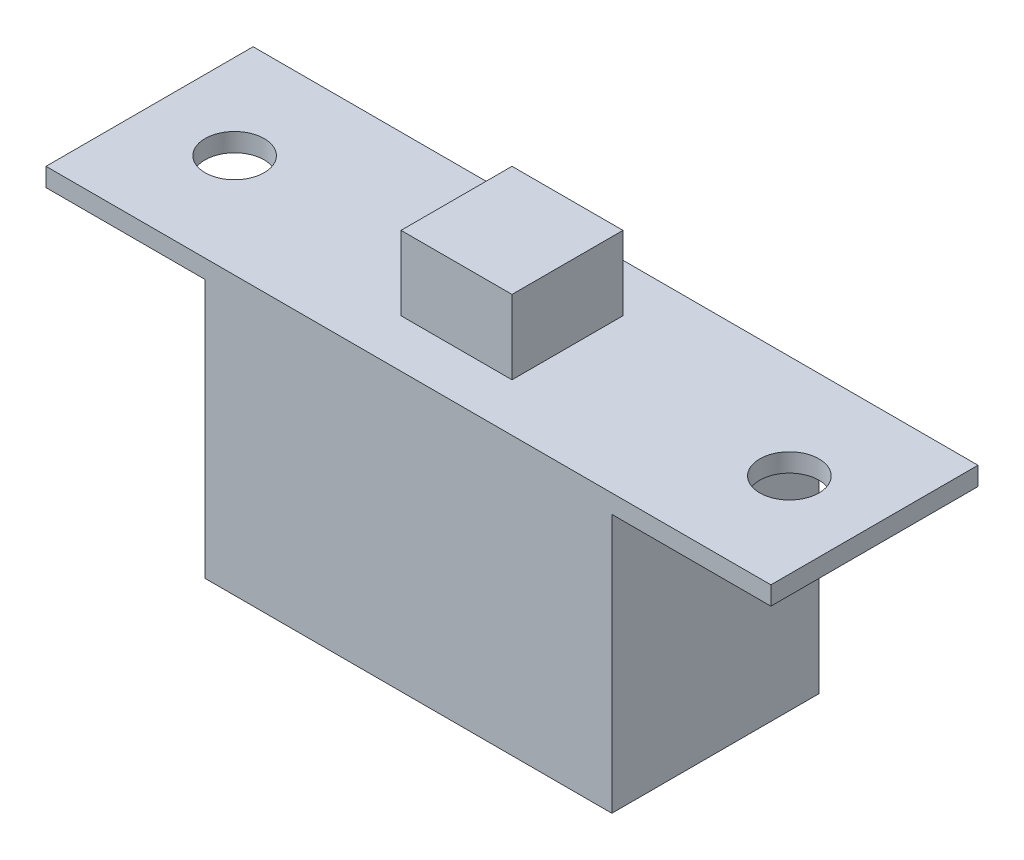
from build123d import *

# Parameters (mm, degrees)
AUFSATZ_LINEAR_AUSTRAGEN1_DEPTH = 2.8
SCHNITT_LINEAR_START            = 1.5
SKIZZE2_W                       = 3
SKIZZE2_H                       = 2
SCHNITT_LINEAR_AUSTRAGEN1_DEPTH = 2.3
M2_GEWINDEBOHRUNG1_D            = 1.6


with BuildPart() as part:
    # Skizze1 → Aufsatz-Linear austragen1 (new body, symmetric)
    with BuildSketch(Plane.XY):
        Polygon((-9.8, -2), (-1.5, -2), (-1.5, 0), (1.5, 0), (1.5, -2), (9.8, -2), (9.8, -2.5), (5.5, -2.5), (5.5, -9.5), (-5.5, -9.5), (-5.5, -2.5), (-9.8, -2.5), align=None)
    extrude(amount=AUFSATZ_LINEAR_AUSTRAGEN1_DEPTH, both=True)

    # Skizze2 → Schnitt-Linear austragen1 (cut, through all)
    with BuildSketch(Plane.XY.offset(SCHNITT_LINEAR_START)):
        with Locations((0, -1)):
            Rectangle(SKIZZE2_W, SKIZZE2_H)
    schnitt_linear_austragen1 = extrude(amount=SCHNITT_LINEAR_AUSTRAGEN1_DEPTH, mode=Mode.SUBTRACT)

    # Spiegeln1: Schnitt-Linear austragen1 across plane
    add(schnitt_linear_austragen1.mirror(Plane.XY), mode=Mode.SUBTRACT)

    # M2 Gewindebohrung1 (through all)
    with Locations(Plane(origin=(0, -2, 0), x_dir=(1, 0, 0), z_dir=(0, 1, 0))):
        with Locations((-7.5, 0), (7.5, 0)):
            Hole(M2_GEWINDEBOHRUNG1_D / 2)


solid = part.part
